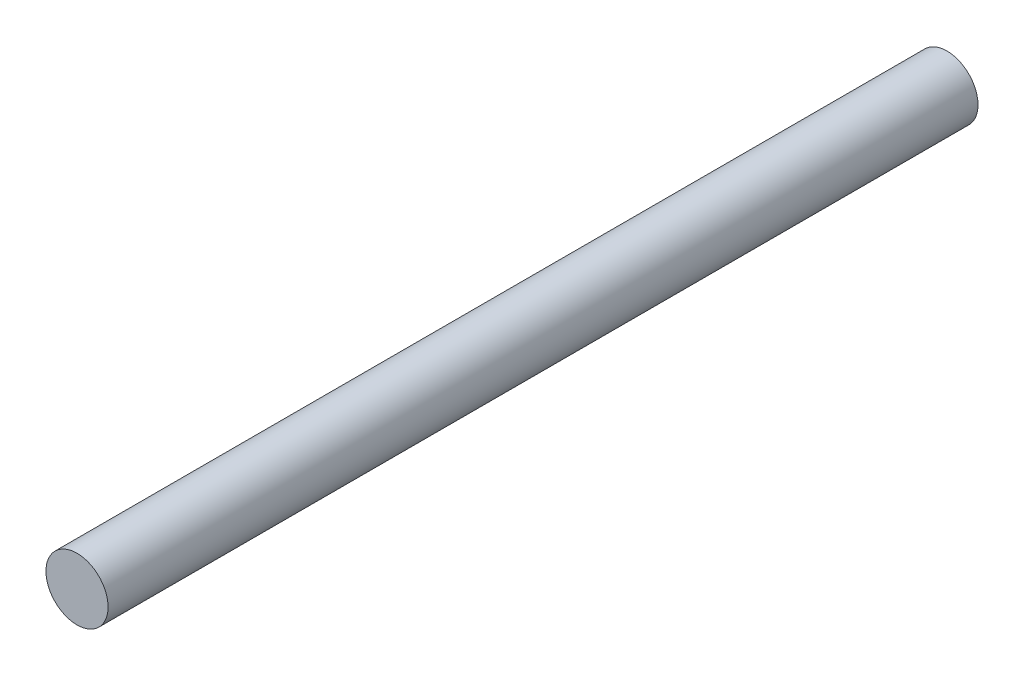
from build123d import *

# Parameters (mm, degrees)
SKETCH1_R           = 3.175
BOSS_EXTRUDE1_DEPTH = 88.9


with BuildPart() as part:
    # Sketch1 → Boss-Extrude1 (new body)
    with BuildSketch(Plane.XY):
        Circle(SKETCH1_R)
    extrude(amount=BOSS_EXTRUDE1_DEPTH)


solid = part.part
